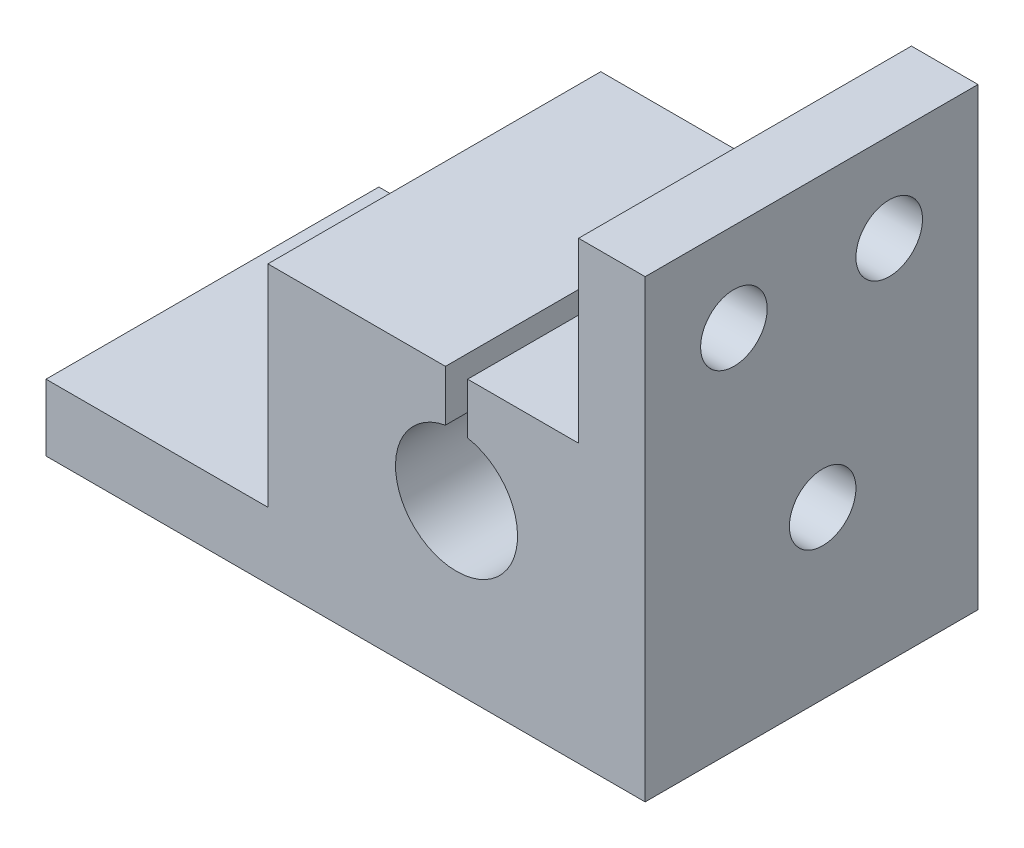
from build123d import *

# Parameters (mm, degrees)
CROQUIS1_W              = 17
CROQUIS1_H              = 15
SALIENTE_EXTRUIR1_DEPTH = 12.5
CROQUIS2_R              = 2.75
CORTAR_EXTRUIR1_DEPTH   = 20
CROQUIS4_R              = 1.5
CORTAR_EXTRUIR3_DEPTH   = 20
CROQUIS8_W              = 15
CROQUIS8_H              = 3
SALIENTE_EXTRUIR2_DEPTH = 10
CROQUIS9_R              = 1.5
CORTAR_EXTRUIR6_DEPTH   = 6
CROQUIS10_W             = 3
CROQUIS10_H             = 15
SALIENTE_EXTRUIR3_DEPTH = 8
CROQUIS11_R             = 1.5
CORTAR_EXTRUIR8_DEPTH   = 6


with BuildPart() as part:
    # Croquis1 → Saliente-Extruir1 (new body)
    with BuildSketch(Plane(origin=(0, 0, 0), x_dir=(1, 0, 0), z_dir=(0, 1, 0))):
        Rectangle(CROQUIS1_W, CROQUIS1_H)
    extrude(amount=SALIENTE_EXTRUIR1_DEPTH)

    # Croquis2 → Cortar-Extruir1 (cut)
    with BuildSketch(Plane(origin=(0, 0, -7.5), x_dir=(-1, 0, 0), z_dir=(0, 0, -1))):
        with Locations((0, 7.5)):
            Circle(CROQUIS2_R)
        with BuildLine():
            Line((0.5, 12.5), (-0.5, 12.5))
            Line((-0.5, 12.5), (-0.5, 10.204163457))
            ThreePointArc((-0.5, 10.204163457), (0, 10.25), (0.5, 10.204163457))
            Line((0.5, 10.204163457), (0.5, 12.5))
        make_face()
    extrude(amount=-CORTAR_EXTRUIR1_DEPTH, mode=Mode.SUBTRACT)

    # Croquis4 → Cortar-Extruir3 (cut)
    with BuildSketch(Plane.ZY.offset(8.5)):
        with Locations((-0.5, 7.5)):
            Circle(CROQUIS4_R)
    extrude(amount=-CORTAR_EXTRUIR3_DEPTH, mode=Mode.SUBTRACT)

    # Croquis8 → Saliente-Extruir2 (add)
    with BuildSketch(Plane.ZY.offset(8.5)):
        with Locations((0, 1.5)):
            Rectangle(CROQUIS8_W, CROQUIS8_H)
    extrude(amount=SALIENTE_EXTRUIR2_DEPTH)

    # Croquis9 → Cortar-Extruir6 (cut)
    with BuildSketch(Plane(origin=(0, 3, 0), x_dir=(1, 0, 0), z_dir=(0, 1, 0))):
        with Locations((-13.5, 0)):
            Circle(CROQUIS9_R)
    extrude(amount=-CORTAR_EXTRUIR6_DEPTH, mode=Mode.SUBTRACT)

    # Croquis10 → Saliente-Extruir3 (add)
    with BuildSketch(Plane(origin=(0, 12.5, 0), x_dir=(1, 0, 0), z_dir=(0, 1, 0))):
        with Locations((7, 0)):
            Rectangle(CROQUIS10_W, CROQUIS10_H)
    extrude(amount=SALIENTE_EXTRUIR3_DEPTH)

    # Croquis11 → Cortar-Extruir8 (cut)
    with BuildSketch(Plane.ZY.offset(-5.5)):
        with Locations((3.5, 16.5)):
            Circle(CROQUIS11_R)
        with Locations((-3.5, 16.5)):
            Circle(CROQUIS11_R)
    extrude(amount=-CORTAR_EXTRUIR8_DEPTH, mode=Mode.SUBTRACT)


solid = part.part
